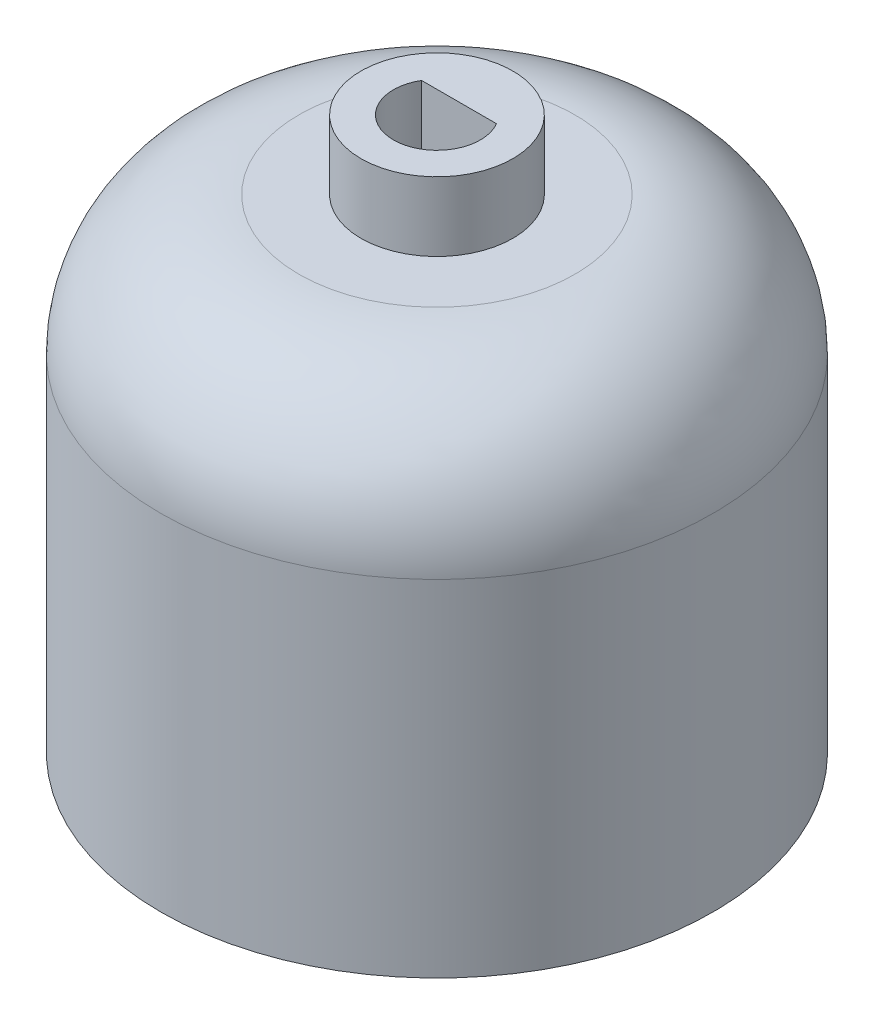
from build123d import *

# Parameters (mm, degrees)
SKETCH1_R           = 20
BOSS_EXTRUDE1_DEPTH = 30
SKETCH2_R           = 20
BOSS_EXTRUDE2_DEPTH = 5
SKETCH3_R           = 5.5
BOSS_EXTRUDE3_DEPTH = 5
FILLET1_R           = 10


with BuildPart() as part:
    # Sketch1 → Boss-Extrude1 (new body)
    with BuildSketch(Plane(origin=(0, 0, 0), x_dir=(1, 0, 0), z_dir=(0, 1, 0))):
        Circle(SKETCH1_R)
        with BuildLine():
            Line((-4.4, 17.6), (4.4, 17.6))
            Line((4.4, 17.6), (4.4, 12.073214154))
            ThreePointArc((4.4, 12.073214154), (0, -12.85), (-4.4, 12.073214154))
            Line((-4.4, 12.073214154), (-4.4, 17.6))
        make_face(mode=Mode.SUBTRACT)
    extrude(amount=BOSS_EXTRUDE1_DEPTH)

    # Sketch2 → Boss-Extrude2 (add)
    with BuildSketch(Plane(origin=(0, 30, 0), x_dir=(1, 0, 0), z_dir=(0, 1, 0))):
        Circle(SKETCH2_R)
    extrude(amount=BOSS_EXTRUDE2_DEPTH)

    # Sketch3 → Boss-Extrude3 (add)
    with BuildSketch(Plane(origin=(0, 35, 0), x_dir=(1, 0, 0), z_dir=(0, 1, 0))):
        Circle(SKETCH3_R)
        with BuildLine():
            Line((-2.71339271, 1.6), (2.71339271, 1.6))
            ThreePointArc((2.71339271, 1.6), (0, -3.15), (-2.71339271, 1.6))
        make_face(mode=Mode.SUBTRACT)
    extrude(amount=BOSS_EXTRUDE3_DEPTH)

    # Fillet1
    fillet1_edges = [part.edges().sort_by_distance(p)[0] for p in [
        (-20, 35, 0),
    ]]
    fillet(fillet1_edges, radius=FILLET1_R)


solid = part.part
